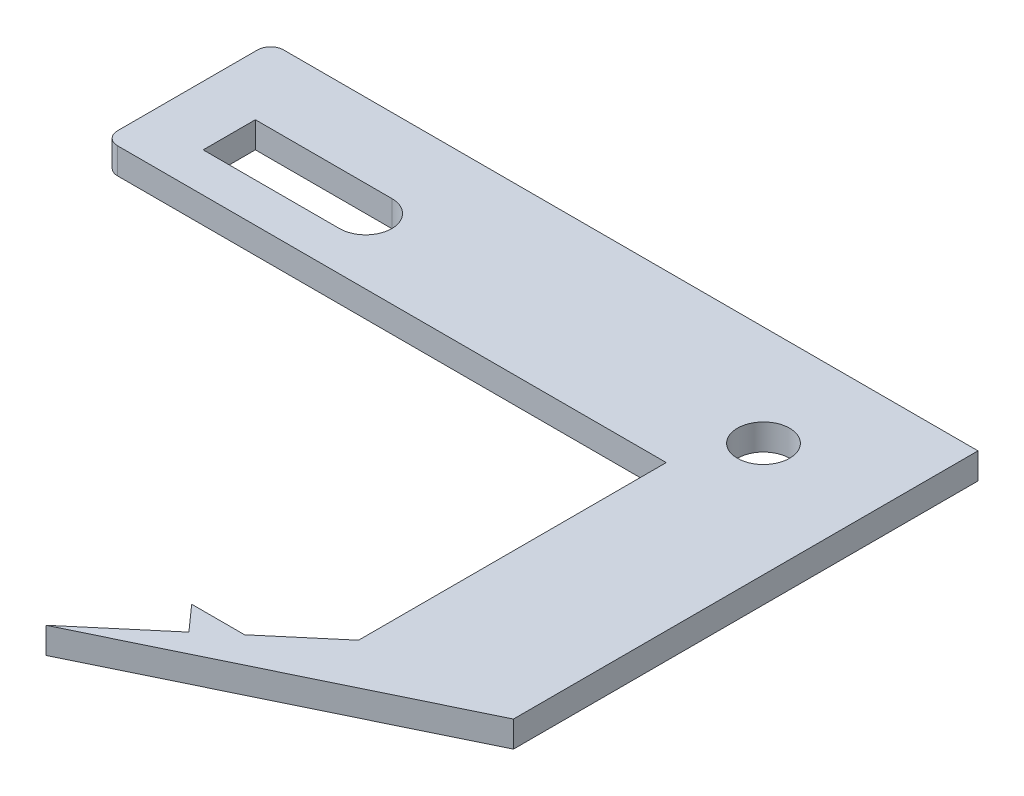
from build123d import *

# Parameters (mm, degrees)
SKETCH1_R           = 2
BOSS_EXTRUDE2_DEPTH = 2


with BuildPart() as part:
    # Sketch1 → Boss-Extrude2 (new body)
    with BuildSketch(Plane(origin=(0, 0, 0), x_dir=(1, 0, 0), z_dir=(0, 1, 0))):
        with BuildLine():
            Line((0, 48.412862342), (0, 37.692030173))
            ThreePointArc((0, 37.692030173), (0.292893219, 36.984923392), (1, 36.692030173))
            Line((1, 36.692030173), (31.48, 36.692030173))
            Line((31.48, 36.692030173), (43.036527631, 36.692030173))
            Line((43.036527631, 36.692030173), (43.036527631, 25.986950269))
            Line((43.036527631, 25.986950269), (43.036527631, 17.132198258))
            Line((43.036527631, 17.132198258), (43.036527631, 13.116497362))
            Line((43.036527631, 13.116497362), (38.310297741, 9.113727486))
            Line((38.310297741, 9.113727486), (34.253582629, 9.113727486))
            Line((34.253582629, 9.113727486), (36, 7.157074844))
            Line((36, 7.157074844), (30.071702425, 2.136241855))
            Line((30.071702425, 2.136241855), (54.200832168, 13.821577266))
            Line((54.200832168, 13.821577266), (54.200832168, 36.692030173))
            Line((54.200832168, 36.692030173), (54.200832168, 49.412862342))
            Line((54.200832168, 49.412862342), (41.48, 49.412862342))
            Line((41.48, 49.412862342), (1, 49.412862342))
            ThreePointArc((1, 49.412862342), (0.292893219, 49.119969123), (0, 48.412862342))
        make_face()
        with Locations((45.48, 41.700609081)):
            Circle(SKETCH1_R, mode=Mode.SUBTRACT)
        with BuildLine():
            Line((15, 43.700609081), (4.549516448, 43.700609081))
            Line((4.549516448, 43.700609081), (4.549516448, 39.700609081))
            Line((4.549516448, 39.700609081), (15, 39.700609081))
            ThreePointArc((15, 39.700609081), (17, 41.700609081), (15, 43.700609081))
        make_face(mode=Mode.SUBTRACT)
    extrude(amount=BOSS_EXTRUDE2_DEPTH)


solid = part.part
